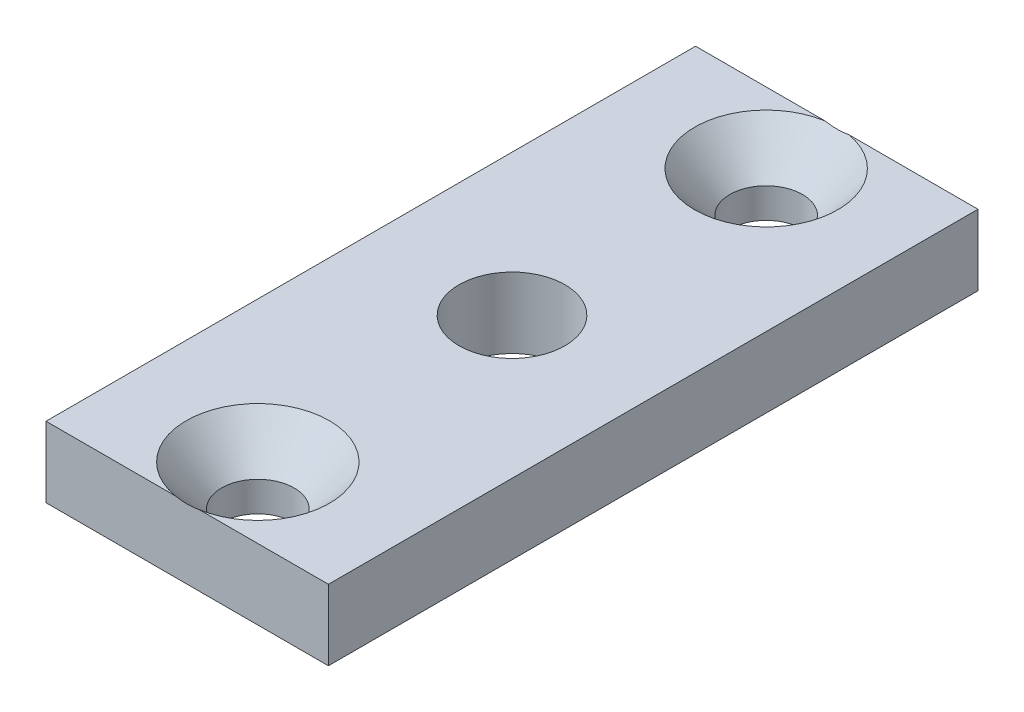
from build123d import *

# Parameters (mm, degrees)
SKETCH1_W                                     = 25.4
SKETCH1_H                                     = 6.35
EXTRUDE1_DEPTH                                = 58.42
CSK_FOR_1_4_FLAT_HEAD_MACHINE_SCREW1_AT_COUNT = 2
CSK_FOR_1_4_FLAT_HEAD_MACHINE_SCREW1_AT_PITCH = 45.72
F_3_8_0_375_DIAMETER_HOLE1_D                  = 9.525


with BuildPart() as part:
    # Sketch1 → Extrude1 (new body)
    with BuildSketch(Plane.XY):
        Rectangle(SKETCH1_W, SKETCH1_H)
    extrude(amount=EXTRUDE1_DEPTH)

    # Sketch3 → CSK for 1/4 Flat Head Machine Screw1 (revolve, cut)
    with BuildSketch(Plane(origin=(0, 3.175, 6.35), x_dir=(0, 0, 1), z_dir=(1, 0, 0))):
        Polygon((0, 0), (0, 6.35), (3.2639, 6.35), (3.2639, 3.652419693), (6.4389, 0), align=None)
    csk_for_1_4_flat_head_machine_screw1 = revolve(axis=Axis((0, 9.525, 6.35), (0, -1, 0)), mode=Mode.SUBTRACT)

    # CSK for 1/4 Flat Head Machine Screw1 at: CSK for 1/4 Flat Head Machine Screw1 ×2
    with Locations(*[(0, 0, i * CSK_FOR_1_4_FLAT_HEAD_MACHINE_SCREW1_AT_PITCH) for i in range(1, CSK_FOR_1_4_FLAT_HEAD_MACHINE_SCREW1_AT_COUNT)]):
        add(csk_for_1_4_flat_head_machine_screw1, mode=Mode.SUBTRACT)

    # 3/8 (0.375) Diameter Hole1 (through all)
    with Locations(Plane(origin=(0, 3.175, 29.21), x_dir=(0, 0, 1), z_dir=(0, 1, 0))):
        with Locations((0, 0)):
            Hole(F_3_8_0_375_DIAMETER_HOLE1_D / 2)


solid = part.part
